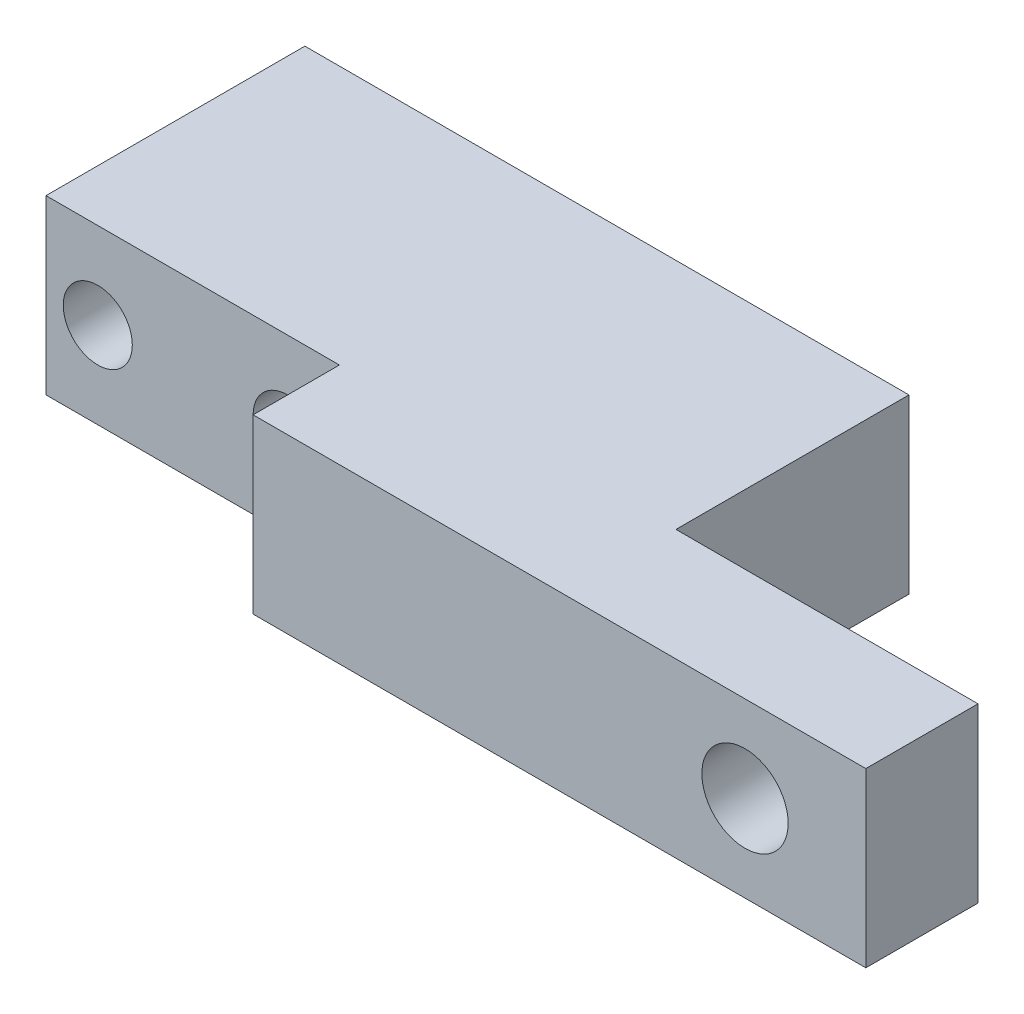
from build123d import *

# Parameters (mm, degrees)
ESQUISSE1_W      = 52.5
ESQUISSE1_H      = 10
EXTRUSION1_DEPTH = 20
ESQUISSE3_R      = 2
EXTRUSION3_DEPTH = 21
ESQUISSE4_R      = 2.5
EXTRUSION4_DEPTH = 20
ESQUISSE2_W      = 17
ESQUISSE2_H      = 5
ESQUISSE2_W_2    = 17.5
ESQUISSE2_H_2    = 13.5
EXTRUSION5_DEPTH = 20


with BuildPart() as part:
    # Esquisse1 → Extrusion1 (new body)
    with BuildSketch(Plane.XY):
        with Locations((26.25, -5)):
            Rectangle(ESQUISSE1_W, ESQUISSE1_H)
    extrude(amount=EXTRUSION1_DEPTH)

    # Esquisse3 → Extrusion3 (cut, through all)
    with BuildSketch(Plane.XY.offset(20)):
        with Locations((3, -5)):
            Circle(ESQUISSE3_R)
        with Locations((14, -5)):
            Circle(ESQUISSE3_R)
    extrude(amount=-EXTRUSION3_DEPTH, mode=Mode.SUBTRACT)

    # Esquisse4 → Extrusion4 (cut)
    with BuildSketch(Plane.XY.offset(20)):
        with Locations((45.5, -5)):
            Circle(ESQUISSE4_R)
    extrude(amount=-EXTRUSION4_DEPTH, mode=Mode.SUBTRACT)

    # Esquisse2 → Extrusion5 (cut)
    with BuildSketch(Plane(origin=(0, 0, 0), x_dir=(1, 0, 0), z_dir=(0, 1, 0))):
        with Locations((8.5, -17.5)):
            Rectangle(ESQUISSE2_W, ESQUISSE2_H)
        with Locations((43.75, -6.75)):
            Rectangle(ESQUISSE2_W_2, ESQUISSE2_H_2)
    extrude(amount=-EXTRUSION5_DEPTH, mode=Mode.SUBTRACT)


solid = part.part
